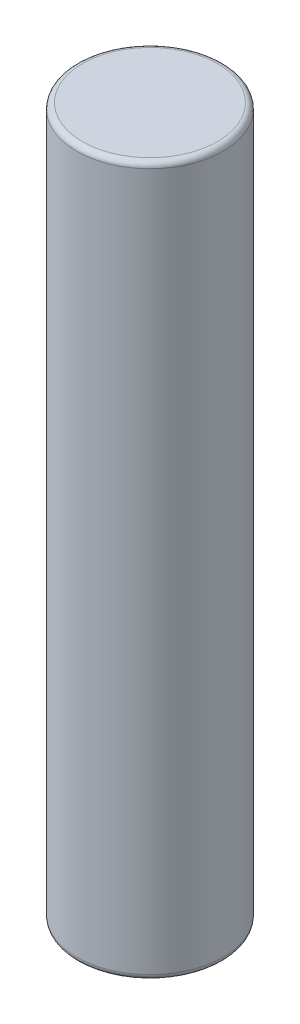
from build123d import *

# Parameters (mm, degrees)
SKETCH1_R           = 6.5
BOSS_EXTRUDE1_DEPTH = 63
FILLET1_R           = 0.5


with BuildPart() as part:
    # Sketch1 → Boss-Extrude1 (new body)
    with BuildSketch(Plane(origin=(0, 0, 0), x_dir=(1, 0, 0), z_dir=(0, 1, 0))):
        Circle(SKETCH1_R)
    extrude(amount=BOSS_EXTRUDE1_DEPTH)

    # Fillet1
    fillet1_edges = [part.edges().sort_by_distance(p)[0] for p in [
        (-6.5, 0, 0),
        (-6.5, 63, 0),
    ]]
    fillet(fillet1_edges, radius=FILLET1_R)


solid = part.part
